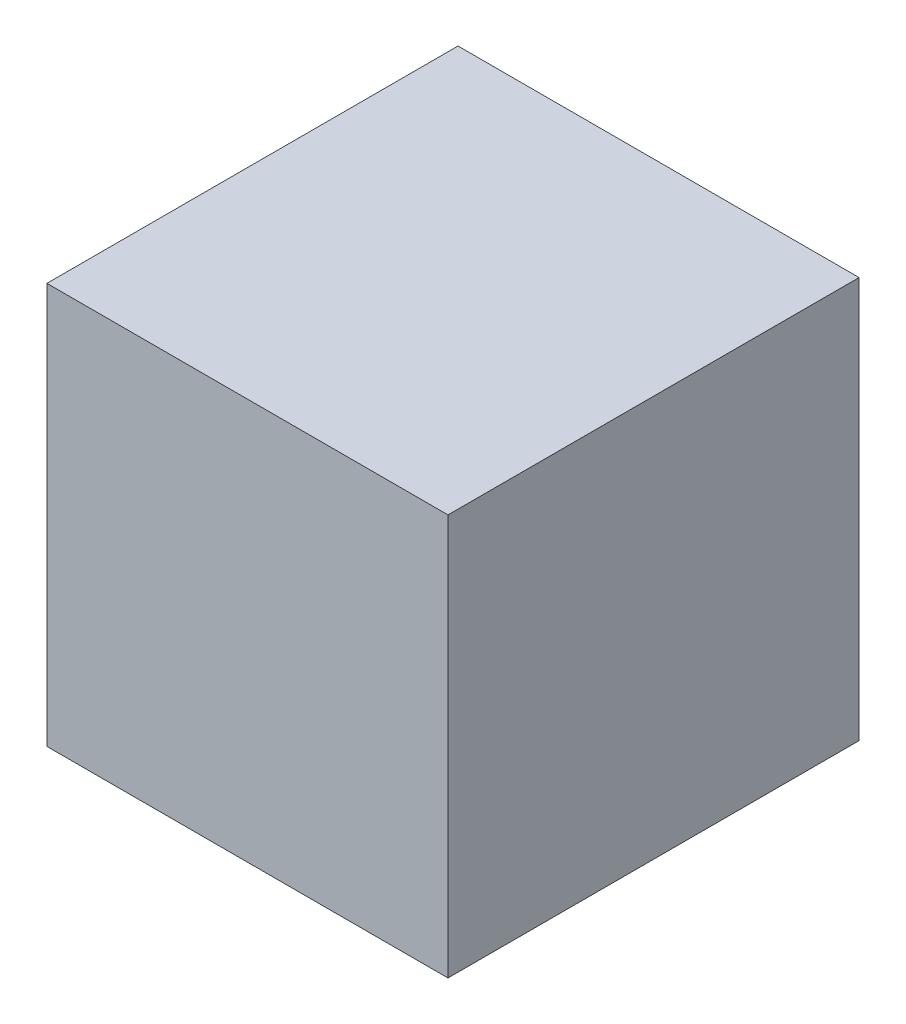
from build123d import *

# Parameters (mm, degrees)
SKETCH1_W           = 200
SKETCH1_H           = 200
SKETCH1_W_2         = 190
SKETCH1_H_2         = 190
BOSS_EXTRUDE1_DEPTH = 200
SKETCH2_W           = 200
SKETCH2_H           = 200
BOSS_EXTRUDE2_DEPTH = 5
SKETCH3_R           = 2.5
CUT_EXTRUDE1_DEPTH  = 6


with BuildPart() as part:
    # Sketch1 → Boss-Extrude1 (new body)
    with BuildSketch(Plane.XY):
        Rectangle(SKETCH1_W, SKETCH1_H)
        Rectangle(SKETCH1_W_2, SKETCH1_H_2, mode=Mode.SUBTRACT)
    extrude(amount=BOSS_EXTRUDE1_DEPTH)

    # Sketch2 → Boss-Extrude2 (add)
    with BuildSketch(Plane.XY.offset(200)):
        Rectangle(SKETCH2_W, SKETCH2_H)
    extrude(amount=BOSS_EXTRUDE2_DEPTH)

    # Sketch3 → Cut-Extrude1 (cut)
    with BuildSketch(Plane.XZ.offset(100)):
        with Locations((13, 5)):
            Circle(SKETCH3_R)
        with Locations((-13, 5)):
            Circle(SKETCH3_R)
    extrude(amount=-CUT_EXTRUDE1_DEPTH, mode=Mode.SUBTRACT)


solid = part.part
